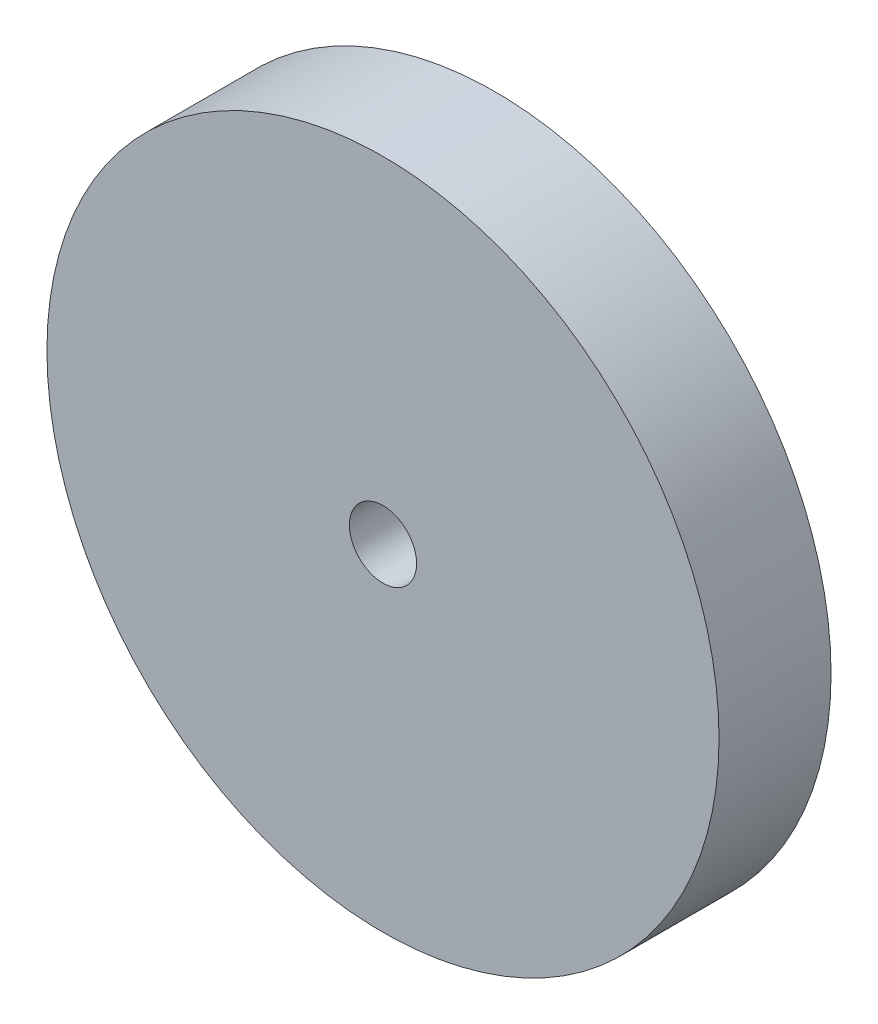
from build123d import *

# Parameters (mm, degrees)
SKETCH1_R           = 60
BOSS_EXTRUDE1_DEPTH = 20
SKETCH2_R           = 6
CUT_EXTRUDE1_DEPTH  = 21


with BuildPart() as part:
    # Sketch1 → Boss-Extrude1 (new body)
    with BuildSketch(Plane.XY):
        Circle(SKETCH1_R)
    extrude(amount=BOSS_EXTRUDE1_DEPTH)

    # Sketch2 → Cut-Extrude1 (cut, through all)
    with BuildSketch(Plane.XY.offset(20)):
        Circle(SKETCH2_R)
    extrude(amount=-CUT_EXTRUDE1_DEPTH, mode=Mode.SUBTRACT)


solid = part.part
